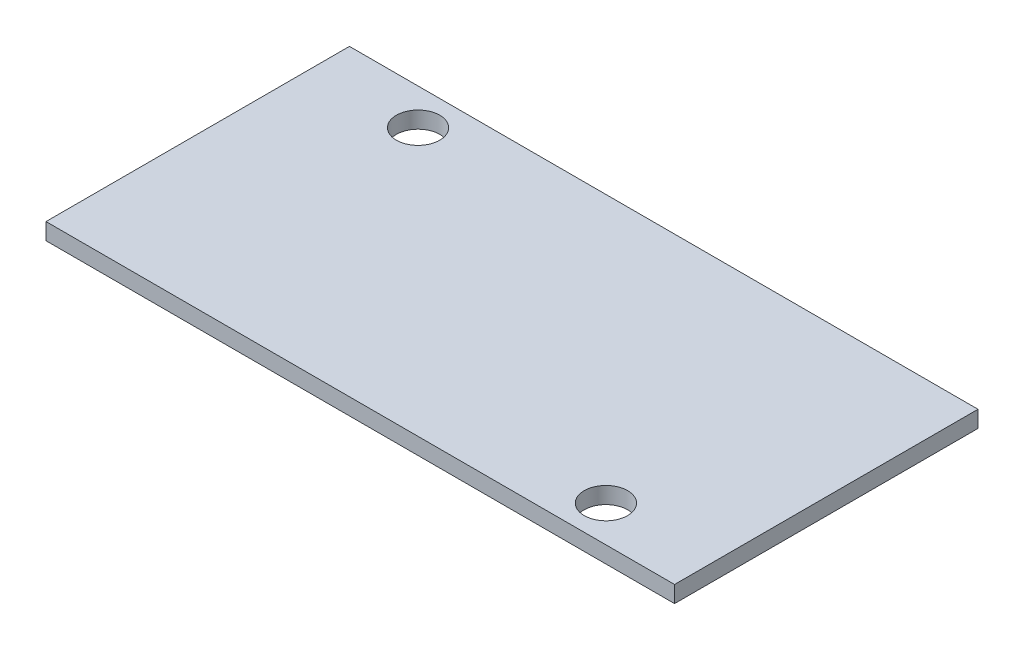
from build123d import *

# Parameters (mm, degrees)
SKETCH1_W           = 43.5
SKETCH1_H           = 21
SKETCH1_R           = 1.5
BOSS_EXTRUDE1_DEPTH = 1.15


with BuildPart() as part:
    # Sketch1 → Boss-Extrude1 (new body)
    with BuildSketch(Plane(origin=(0, 0, 0), x_dir=(1, 0, 0), z_dir=(0, 1, 0))):
        Rectangle(SKETCH1_W, SKETCH1_H)
        with Locations((-14.5, 8)):
            Circle(SKETCH1_R, mode=Mode.SUBTRACT)
        with Locations((14.5, -8)):
            Circle(SKETCH1_R, mode=Mode.SUBTRACT)
    extrude(amount=BOSS_EXTRUDE1_DEPTH)


solid = part.part
